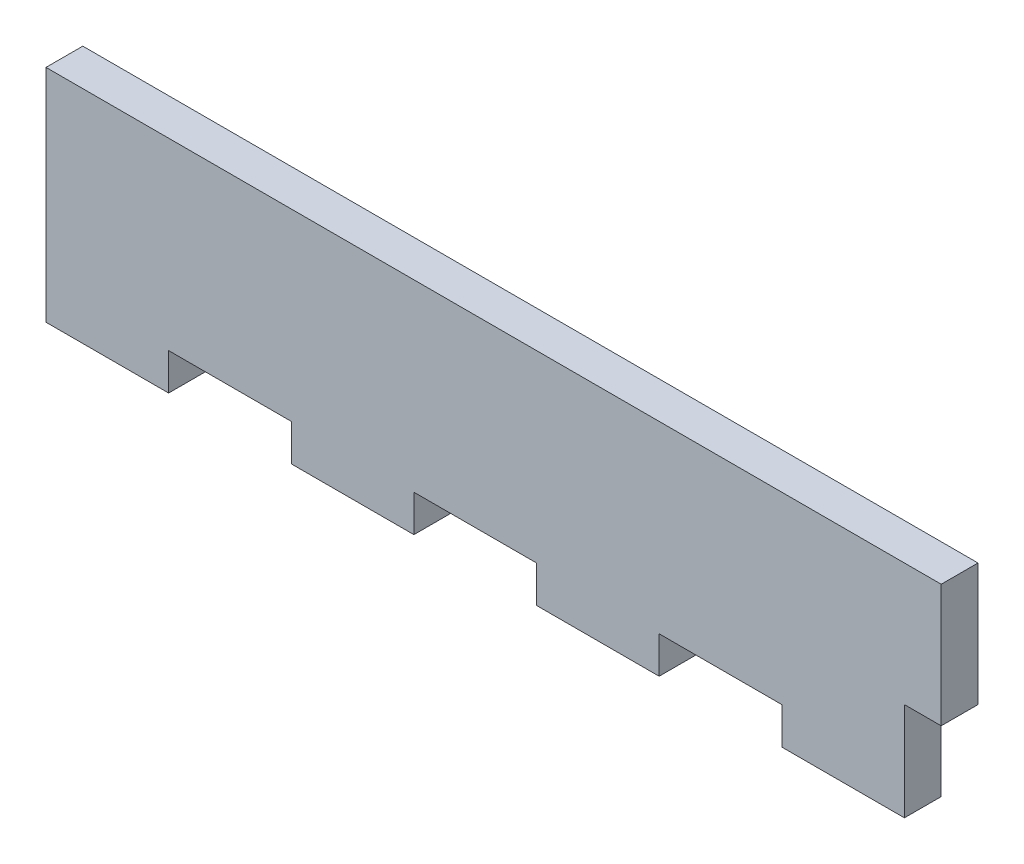
from build123d import *

# Parameters (mm, degrees)
ESQUISSE1_W                = 70
ESQUISSE1_H                = 18
BOSS_EXTRU_1_DEPTH         = 3
ESQUISSE2_W                = 10
ESQUISSE2_H                = 3
ENL_V_MAT_EXTRU_1_DEPTH    = 3
R_P_TITION_LIN_AIRE1_COUNT = 3
R_P_TITION_LIN_AIRE1_PITCH = 20
ESQUISSE3_W                = 3
ESQUISSE3_H                = 10
BOSS_EXTRU_2_DEPTH         = 3


with BuildPart() as part:
    # Esquisse1 → Boss.-Extru.1 (new body)
    with BuildSketch(Plane.XY):
        with Locations((35, -9)):
            Rectangle(ESQUISSE1_W, ESQUISSE1_H)
    extrude(amount=BOSS_EXTRU_1_DEPTH)

    # Esquisse2 → Enlèv. mat.-Extru.1 (cut)
    with BuildSketch(Plane.XY.offset(3)):
        with Locations((55, -16.5)):
            Rectangle(ESQUISSE2_W, ESQUISSE2_H)
    enl_v_mat_extru_1 = extrude(amount=-ENL_V_MAT_EXTRU_1_DEPTH, mode=Mode.SUBTRACT)

    # Répétition linéaire1: Enlèv. mat.-Extru.1 ×3
    with Locations(*[(-i * R_P_TITION_LIN_AIRE1_PITCH, 0, 0) for i in range(1, R_P_TITION_LIN_AIRE1_COUNT)]):
        add(enl_v_mat_extru_1, mode=Mode.SUBTRACT)

    # Esquisse3 → Boss.-Extru.2 (add)
    with BuildSketch(Plane(origin=(70, 0, 0), x_dir=(0, 0, -1), z_dir=(1, 0, 0))):
        with Locations((-1.5, -5)):
            Rectangle(ESQUISSE3_W, ESQUISSE3_H)
    extrude(amount=BOSS_EXTRU_2_DEPTH)


solid = part.part
